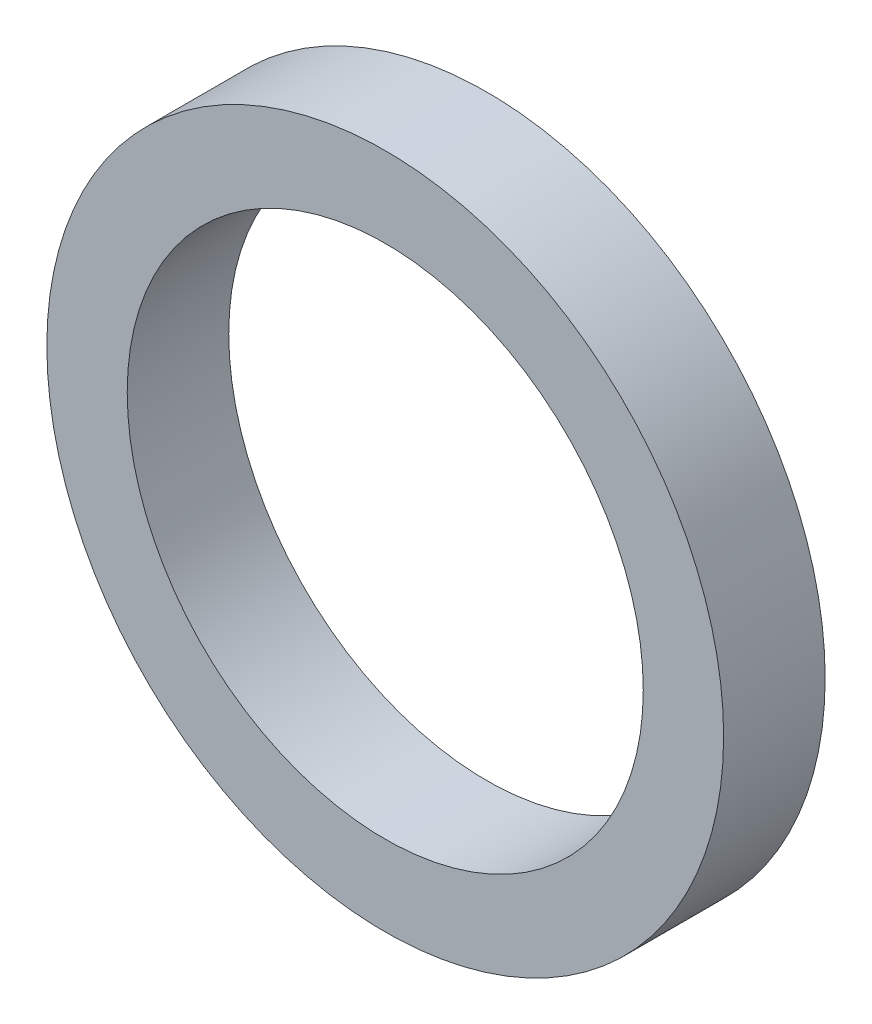
from build123d import *

# Parameters (mm, degrees)
SKETCH1_R           = 20
BOSS_EXTRUDE1_DEPTH = 6
SKETCH2_R           = 15.25
CUT_EXTRUDE1_DEPTH  = 7


with BuildPart() as part:
    # Sketch1 → Boss-Extrude1 (new body)
    with BuildSketch(Plane.XY):
        Circle(SKETCH1_R)
    extrude(amount=BOSS_EXTRUDE1_DEPTH)

    # Sketch2 → Cut-Extrude1 (cut, through all)
    with BuildSketch(Plane(origin=(0, 0, 0), x_dir=(-1, 0, 0), z_dir=(0, 0, -1))):
        Circle(SKETCH2_R)
    extrude(amount=-CUT_EXTRUDE1_DEPTH, mode=Mode.SUBTRACT)


solid = part.part
